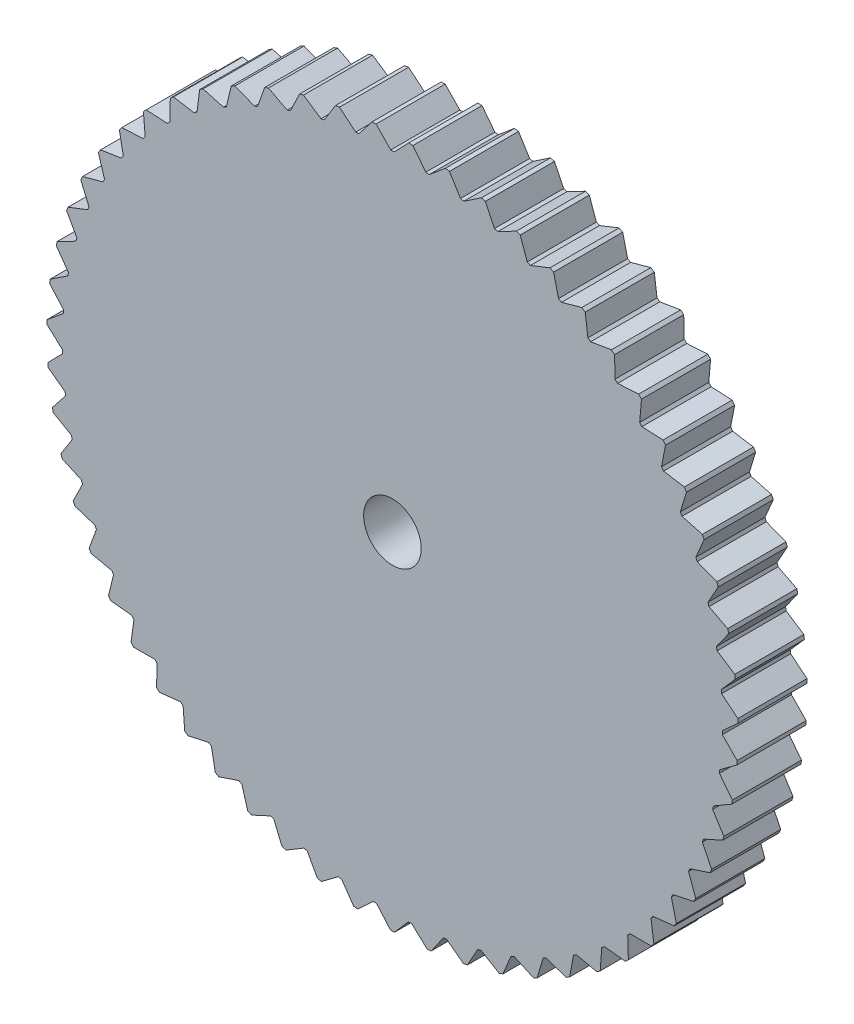
from build123d import *

# Parameters (mm, degrees)
SKETCH1_R           = 60
SKETCH1_R_2         = 5
BOSS_EXTRUDE1_DEPTH = 12
CUT_EXTRUDE1_DEPTH  = 12


with BuildPart() as part:
    # Sketch1 → Boss-Extrude1 (new body)
    with BuildSketch(Plane.XY):
        Circle(SKETCH1_R)
        Circle(SKETCH1_R_2, mode=Mode.SUBTRACT)
    extrude(amount=BOSS_EXTRUDE1_DEPTH)

    # Sketch2 → Cut-Extrude1 (cut)
    with BuildSketch(Plane.XY.offset(12)):
        Polygon((-3, 60.1), (-0.3, 57.3), (0.3, 57.3), (3, 60.1), align=None)
        Polygon((3.405234087, 60.07840195), (5.792316288, 57.007272098), (6.388917168, 56.943496006), (9.371242888, 59.440641036), align=None)
        Polygon((9.771885511, 59.376091599), (11.819003317, 56.068629024), (12.405445351, 55.941799449), (15.63630585, 58.107795857), align=None)
        Polygon((16.027817567, 58.001026405), (17.711776316, 54.494705979), (18.281414881, 54.306259952), (21.724203218, 56.116566133), align=None)
        Polygon((22.102148046, 55.968786406), (23.403867813, 52.30333614), (23.950248676, 52.055408829), (27.565956683, 53.489513291), align=None)
        Polygon((27.926052356, 53.302397693), (28.830784135, 49.519348604), (29.347716584, 49.214749124), (33.095376845, 50.256402891), align=None)
        Polygon((33.433543334, 50.032071515), (33.931036153, 46.174287061), (34.412663136, 45.816466646), (38.249813162, 46.453867364), align=None)
        Polygon((38.562218907, 46.194861976), (38.646835973, 42.306052395), (39.087700464, 41.899065294), (42.970863812, 42.124990958), align=None)
        Polygon((43.253969131, 41.834246191), (42.924751699, 37.958473251), (43.319858526, 37.506930789), (47.205037406, 37.318821572), align=None)
        Polygon((47.455634601, 36.999631682), (46.716312836, 33.180809438), (47.061185283, 32.689827773), (50.904359063, 32.089815026), align=None)
        Polygon((51.119608769, 31.745796561), (49.978559483, 28.027193795), (50.269290005, 27.502335945), (54.026913991, 26.497218053), align=None)
        Polygon((54.204377344, 26.13226888), (52.674529079, 22.556018848), (52.907823585, 22.003231661), (56.537322396, 20.604397012), align=None)
        Polygon((56.674988664, 20.22265215), (54.773675214, 16.829275194), (54.946890382, 16.254821971), (58.407140348, 14.47811992), align=None)
        Polygon((58.503449716, 14.083904691), (56.252213722, 10.911849128), (56.363386956, 10.322238653), (59.61518206, 8.187799944), align=None)
        Polygon((59.669043306, 7.785580965), (57.093392171, 4.87078745), (57.141263835, 4.272700246), (60.147759939, 1.804708923), align=None)
        Polygon((60.158562793, 1.399043495), (57.287679674, -1.225462195), (57.271707361, -1.825249562), (59.998839664, -4.598830172), align=None)
        Polygon((59.966461725, -5.003345697), (56.832874875, -7.307826864), (56.753239558, -7.902518563), (59.170108561, -10.950262683), align=None)
        Polygon((59.094916685, -11.349044982), (55.734130894, -13.307390935), (55.591734874, -13.890248871), (57.670956486, -17.177624342), align=None)
        Polygon((57.553802625, -17.566155054), (54.00389694, -19.156176949), (53.80035362, -19.720597109), (55.518369429, -23.210356654), align=None)
        Polygon((55.360580985, -23.584233569), (51.661777255, -24.787915823), (51.399392863, -25.327503101), (52.736737062, -28.98010635), align=None)
        Polygon((52.540101841, -29.335093294), (48.734308991, -30.138797707), (48.416056446, -30.647438364), (49.357576392, -34.421499862), align=None)
        Polygon((49.124322349, -34.753574691), (45.254661532, -35.14819497), (44.884146763, -35.620125903), (45.419174659, -39.472884026), align=None)
        Polygon((45.151944655, -39.778284199), (41.262260675, -39.759349139), (40.843681763, -40.189223183), (40.966155529, -44.077024641), align=None)
        Polygon((40.667977387, -44.352289853), (36.802341918, -43.920013995), (36.340441528, -44.302960506), (36.048973487, -48.181754955), align=None)
        Polygon((35.723225685, -48.423766341), (31.925437921, -47.583047544), (31.425449569, -47.914727583), (30.723342171, -51.740566733), align=None)
        Polygon((30.373715562, -51.946582207), (26.686805956, -50.70694615), (26.154394711, -50.983601651), (25.049603112, -54.713137215), align=None)
        Polygon((24.680059105, -54.880822539), (21.145801815, -53.256314795), (20.587000109, -53.474811141), (19.09204204, -57.065785991), align=None)
        Polygon((18.706767717, -57.193241223), (15.365207291, -55.202268114), (14.78634657, -55.360129652), (12.918160504, -58.771856608), align=None)
        Polygon((12.521521175, -58.857637631), (9.410518828, -56.522757677), (8.818157815, -56.618195774), (6.597911047, -59.812018607), align=None)
        Polygon((6.194400795, -59.855153486), (3.349205427, -57.20282181), (2.75005581, -57.234755115), (0.202904621, -60.174486535), align=None)
        Polygon((-0.202904621, -60.174486535), (-2.75005581, -57.234755115), (-3.349205427, -57.20282181), (-6.194400795, -59.855153486), align=None)
        Polygon((-6.597911047, -59.812018607), (-8.818157815, -56.618195774), (-9.410518828, -56.522757677), (-12.521521175, -58.857637631), align=None)
        Polygon((-12.918160504, -58.771856608), (-14.78634657, -55.360129652), (-15.365207291, -55.202268114), (-18.706767717, -57.193241223), align=None)
        Polygon((-19.09204204, -57.065785991), (-20.587000109, -53.474811141), (-21.145801815, -53.256314795), (-24.680059105, -54.880822539), align=None)
        Polygon((-25.049603112, -54.713137215), (-26.154394711, -50.983601651), (-26.686805956, -50.70694615), (-30.373715562, -51.946582207), align=None)
        Polygon((-30.723342171, -51.740566733), (-31.425449569, -47.914727583), (-31.925437921, -47.583047544), (-35.723225685, -48.423766341), align=None)
        Polygon((-36.048973487, -48.181754955), (-36.340441528, -44.302960506), (-36.802341918, -43.920013995), (-40.667977387, -44.352289853), align=None)
        Polygon((-40.966155529, -44.077024641), (-40.843681763, -40.189223183), (-41.262260675, -39.759349139), (-45.151944655, -39.778284199), align=None)
        Polygon((-45.419174659, -39.472884026), (-44.884146763, -35.620125903), (-45.254661532, -35.14819497), (-49.124322349, -34.753574691), align=None)
        Polygon((-49.357576392, -34.421499862), (-48.416056446, -30.647438364), (-48.734308991, -30.138797707), (-52.540101841, -29.335093294), align=None)
        Polygon((-52.736737062, -28.98010635), (-51.399392863, -25.327503101), (-51.661777255, -24.787915823), (-55.360580985, -23.584233569), align=None)
        Polygon((-55.518369429, -23.210356654), (-53.80035362, -19.720597109), (-54.00389694, -19.156176949), (-57.553802625, -17.566155054), align=None)
        Polygon((-57.670956486, -17.177624342), (-55.591734874, -13.890248871), (-55.734130894, -13.307390935), (-59.094916685, -11.349044982), align=None)
        Polygon((-59.170108561, -10.950262683), (-56.753239558, -7.902518563), (-56.832874875, -7.307826864), (-59.966461725, -5.003345697), align=None)
        Polygon((-59.998839664, -4.598830172), (-57.271707361, -1.825249562), (-57.287679674, -1.225462195), (-60.158562793, 1.399043495), align=None)
        Polygon((-60.147759939, 1.804708923), (-57.141263835, 4.272700246), (-57.093392171, 4.87078745), (-59.669043306, 7.785580965), align=None)
        Polygon((-59.61518206, 8.187799944), (-56.363386956, 10.322238653), (-56.252213722, 10.911849128), (-58.503449716, 14.083904691), align=None)
        Polygon((-58.407140348, 14.47811992), (-54.946890382, 16.254821971), (-54.773675214, 16.829275194), (-56.674988664, 20.22265215), align=None)
        Polygon((-56.537322396, 20.604397012), (-52.907823585, 22.003231661), (-52.674529079, 22.556018848), (-54.204377344, 26.13226888), align=None)
        Polygon((-54.026913991, 26.497218053), (-50.269290005, 27.502335945), (-49.978559483, 28.027193795), (-51.119608769, 31.745796561), align=None)
        Polygon((-50.904359063, 32.089815026), (-47.061185283, 32.689827773), (-46.716312836, 33.180809438), (-47.455634601, 36.999631682), align=None)
        Polygon((-47.205037406, 37.318821572), (-43.319858526, 37.506930789), (-42.924751699, 37.958473251), (-43.253969131, 41.834246191), align=None)
        Polygon((-42.970863812, 42.124990958), (-39.087700464, 41.899065294), (-38.646835973, 42.306052395), (-38.562218907, 46.194861976), align=None)
        Polygon((-38.249813162, 46.453867364), (-34.412663136, 45.816466646), (-33.931036153, 46.174287061), (-33.433543334, 50.032071515), align=None)
        Polygon((-33.095376845, 50.256402891), (-29.347716584, 49.214749124), (-28.830784135, 49.519348604), (-27.926052356, 53.302397693), align=None)
        Polygon((-27.565956683, 53.489513291), (-23.950248676, 52.055408829), (-23.403867813, 52.30333614), (-22.102148046, 55.968786406), align=None)
        Polygon((-21.724203218, 56.116566133), (-18.281414881, 54.306259952), (-17.711776316, 54.494705979), (-16.027817567, 58.001026405), align=None)
        Polygon((-15.63630585, 58.107795857), (-12.405445351, 55.941799449), (-11.819003317, 56.068629024), (-9.771885511, 59.376091599), align=None)
        Polygon((-9.371242888, 59.440641036), (-6.388917168, 56.943496006), (-5.792316288, 57.007272098), (-3.405234087, 60.07840195), align=None)
    extrude(amount=-CUT_EXTRUDE1_DEPTH, mode=Mode.SUBTRACT)


solid = part.part
